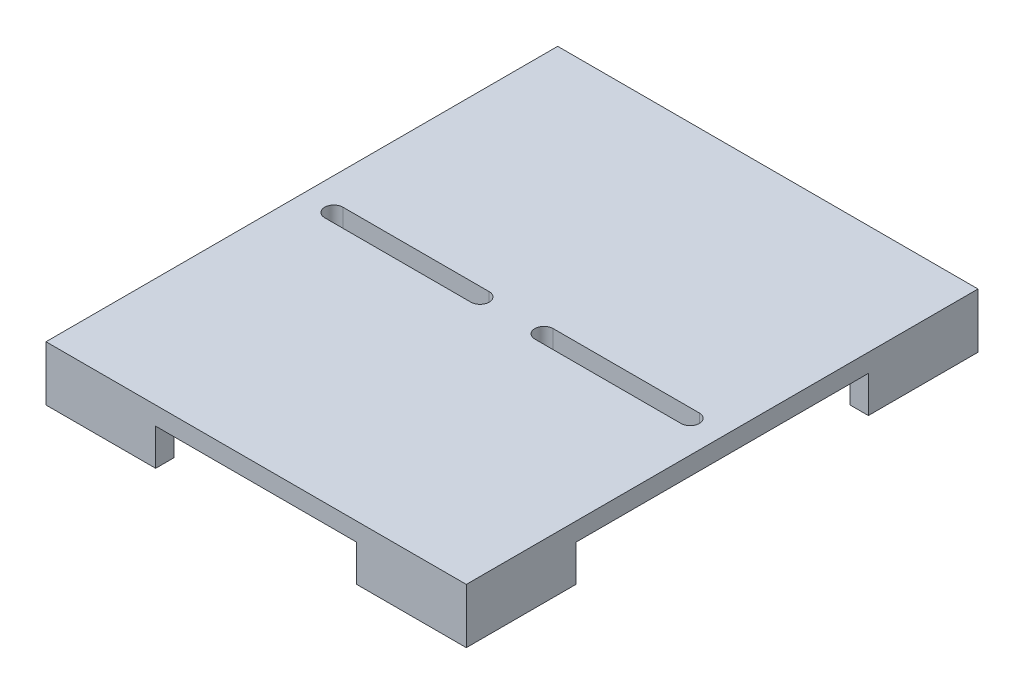
from build123d import *

# Parameters (mm, degrees)
SKETCH1_W           = 292.1
SKETCH1_H           = 355.6
SKETCH1_W_2         = 215.9
SKETCH1_H_2         = 279.4
BOSS_EXTRUDE1_DEPTH = 12.7
CUT_EXTRUDE1_DEPTH  = 13.7
BOSS_EXTRUDE2_DEPTH = 25.4


with BuildPart() as part:
    # Sketch1 → Boss-Extrude1 (new body)
    with BuildSketch(Plane(origin=(0, 0, 0), x_dir=(1, 0, 0), z_dir=(0, 1, 0))):
        Rectangle(SKETCH1_W, SKETCH1_H)
        Polygon((-69.85, 139.7), (69.85, 139.7), (69.85, 152.4), (120.65, 152.4), (120.65, 101.6), (107.95, 101.6), (107.95, -101.6), (120.65, -101.6), (120.65, -152.4), (69.85, -152.4), (69.85, -139.7), (-69.85, -139.7), (-69.85, -152.4), (-120.65, -152.4), (-120.65, -101.6), (-107.95, -101.6), (-107.95, 101.6), (-120.65, 101.6), (-120.65, 152.4), (-69.85, 152.4), align=None, mode=Mode.SUBTRACT)
        Polygon((-107.95, 139.7), (-69.85, 139.7), (-69.85, 152.4), (-120.65, 152.4), (-120.65, 101.6), (-107.95, 101.6), align=None)
        Polygon((-107.95, -139.7), (-107.95, -101.6), (-120.65, -101.6), (-120.65, -152.4), (-69.85, -152.4), (-69.85, -139.7), align=None)
        Rectangle(SKETCH1_W_2, SKETCH1_H_2)
        Polygon((120.65, -101.6), (107.95, -101.6), (107.95, -139.7), (69.85, -139.7), (69.85, -152.4), (120.65, -152.4), align=None)
        Polygon((69.85, 152.4), (69.85, 139.7), (107.95, 139.7), (107.95, 101.6), (120.65, 101.6), (120.65, 152.4), align=None)
    extrude(amount=BOSS_EXTRUDE1_DEPTH)

    # Sketch2 → Cut-Extrude1 (cut, through all)
    with BuildSketch(Plane(origin=(0, 12.7, 0), x_dir=(1, 0, 0), z_dir=(0, 1, 0))):
        with BuildLine():
            Line((-123.825, 6.35), (-22.225, 6.35))
            ThreePointArc((-22.225, 6.35), (-15.875, 0), (-22.225, -6.35))
            Line((-22.225, -6.35), (-123.825, -6.35))
            ThreePointArc((-123.825, -6.35), (-130.175, 0), (-123.825, 6.35))
        make_face()
        with BuildLine():
            Line((123.825, 6.35), (22.225, 6.35))
            ThreePointArc((22.225, 6.35), (15.875, 0), (22.225, -6.35))
            Line((22.225, -6.35), (123.825, -6.35))
            ThreePointArc((123.825, -6.35), (130.175, 0), (123.825, 6.35))
        make_face()
    extrude(amount=-CUT_EXTRUDE1_DEPTH, mode=Mode.SUBTRACT)

    # Sketch3 → Boss-Extrude2 (add)
    with BuildSketch(Plane.XZ):
        Polygon((-69.85, 177.8), (-146.05, 177.8), (-146.05, 101.6), (-133.35, 101.6), (-133.35, 165.1), (-69.85, 165.1), align=None)
        Polygon((146.05, 177.8), (69.85, 177.8), (69.85, 165.1), (133.35, 165.1), (133.35, 101.6), (146.05, 101.6), align=None)
        Polygon((146.05, -177.8), (146.05, -101.6), (133.35, -101.6), (133.35, -165.1), (69.85, -165.1), (69.85, -177.8), align=None)
        Polygon((-133.35, -101.6), (-146.05, -101.6), (-146.05, -177.8), (-69.85, -177.8), (-69.85, -165.1), (-133.35, -165.1), align=None)
    extrude(amount=BOSS_EXTRUDE2_DEPTH)


solid = part.part
